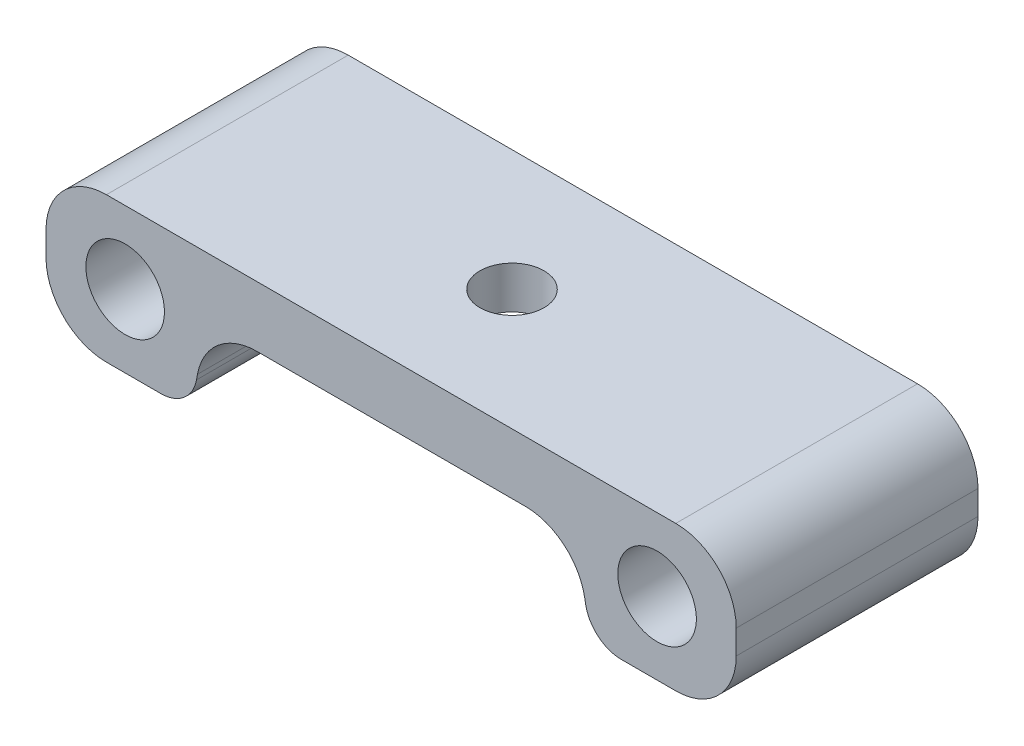
from build123d import *

# Parameters (mm, degrees)
ESQUISSE1_R             = 3.25
BOSS_EXTRU_1_DEPTH      = 10
CONG_1_R                = 5
CONG_2_R                = 3
ESQUISSE2_R             = 6
ENL_V_MAT_EXTRU_1_DEPTH = 1.5
ESQUISSE3_R             = 2.65
ENL_V_MAT_EXTRU_2_DEPTH = 13


with BuildPart() as part:
    # Esquisse1 → Boss.-Extru.1 (new body, symmetric)
    with BuildSketch(Plane.XY):
        Polygon((0, 0), (-15.265735364, 0), (-16.548069585, -7), (-28.548069585, -7), (-28.548069585, 5), (0, 5), align=None)
        with Locations((-22, -1)):
            Circle(ESQUISSE1_R, mode=Mode.SUBTRACT)
    boss_extru_1 = extrude(amount=BOSS_EXTRU_1_DEPTH, both=True)

    # Symétrie1: Boss.-Extru.1 across plane
    add(boss_extru_1.mirror(Plane(origin=(0, 5, 10), x_dir=(0, 0, 1), z_dir=(-1, 0, 0))))

    # Congé1
    cong_1_edges = [part.edges().sort_by_distance(p)[0] for p in [
        (-15.265735364, 0, 0),
        (-28.548069585, -7, 0),
        (-28.548069585, 5, 0),
        (15.265735364, 0, 0),
        (28.548069585, -7, 0),
        (28.548069585, 5, 0),
    ]]
    fillet(cong_1_edges, radius=CONG_1_R)

    # Congé2
    cong_2_edges = [part.edges().sort_by_distance(p)[0] for p in [
        (-16.548069585, -7, 0),
        (16.548069585, -7, 0),
    ]]
    fillet(cong_2_edges, radius=CONG_2_R)

    # Esquisse2 → Enlèv. mat.-Extru.1 (cut)
    with BuildSketch(Plane.XZ):
        Circle(ESQUISSE2_R)
    extrude(amount=-ENL_V_MAT_EXTRU_1_DEPTH, mode=Mode.SUBTRACT)

    # Esquisse3 → Enlèv. mat.-Extru.2 (cut, through all)
    with BuildSketch(Plane(origin=(0, 5, 0), x_dir=(1, 0, 0), z_dir=(0, 1, 0))):
        Circle(ESQUISSE3_R)
    extrude(amount=-ENL_V_MAT_EXTRU_2_DEPTH, mode=Mode.SUBTRACT)


solid = part.part
